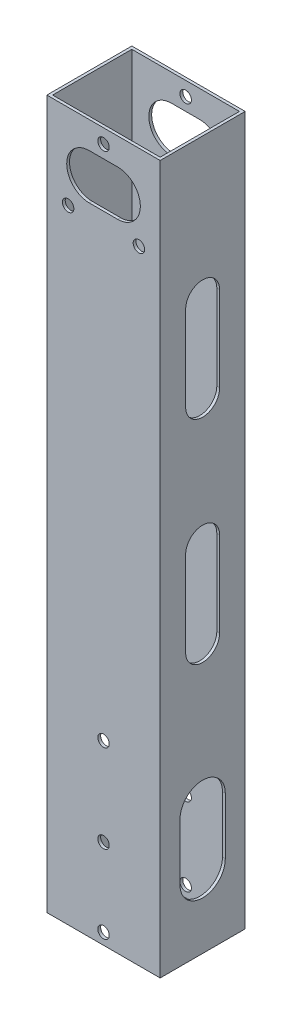
from build123d import *

# Parameters (mm, degrees)
SKETCH_1_W               = 40
SKETCH_1_H               = 30
EXTRUDE_1_DEPTH          = 125
SKETCH_2_W               = 38
SKETCH_2_H               = 28
CUT_EXTRUDE_1_DEPTH      = 126
CUT_EXTRUDE_1_DEPTH_BACK = 126
SKETCH_3_R               = 2.025
CUT_EXTRUDE_2_DEPTH      = 1
CUT_EXTRUDE_2_DEPTH_BACK = 31
SKETCH_4_R               = 2.025
CUT_EXTRUDE_3_DEPTH      = 1
CUT_EXTRUDE_3_DEPTH_BACK = 31
CUT_EXTRUDE_4_DEPTH      = 1
CUT_EXTRUDE_4_DEPTH_BACK = 41
CUT_EXTRUDE_5_DEPTH      = 1
CUT_EXTRUDE_5_DEPTH_BACK = 31
CUT_EXTRUDE_6_DEPTH      = 1
CUT_EXTRUDE_6_DEPTH_BACK = 41


with BuildPart() as part:
    # 草图1 → 凸台-拉伸1 (new body, symmetric)
    with BuildSketch(Plane(origin=(0, 0, 0), x_dir=(1, 0, 0), z_dir=(0, 1, 0))):
        Rectangle(SKETCH_1_W, SKETCH_1_H)
    extrude(amount=EXTRUDE_1_DEPTH, both=True)

    # 草图2 → 切除-拉伸1 (cut, two sides)
    with BuildSketch(Plane(origin=(0, 0, 0), x_dir=(1, 0, 0), z_dir=(0, 1, 0))) as cut_extrude_1_sk:
        Rectangle(SKETCH_2_W, SKETCH_2_H)
    extrude(amount=CUT_EXTRUDE_1_DEPTH, mode=Mode.SUBTRACT)
    extrude(cut_extrude_1_sk.sketch, amount=-CUT_EXTRUDE_1_DEPTH_BACK, mode=Mode.SUBTRACT)

    # 草图3 → 切除-拉伸2 (cut, two sides)
    with BuildSketch(Plane.XY.offset(15)) as cut_extrude_2_sk:
        with Locations((0, -62.433034374)):
            Circle(SKETCH_3_R)
        with Locations((0, -93.433034374)):
            Circle(SKETCH_3_R)
        with Locations((0, -121)):
            Circle(SKETCH_3_R)
    extrude(amount=CUT_EXTRUDE_2_DEPTH, mode=Mode.SUBTRACT)
    extrude(cut_extrude_2_sk.sketch, amount=-CUT_EXTRUDE_2_DEPTH_BACK, mode=Mode.SUBTRACT)

    # 草图4 → 切除-拉伸3 (cut, two sides)
    with BuildSketch(Plane(origin=(0, 0, -15), x_dir=(-1, 0, 0), z_dir=(0, 0, -1))) as cut_extrude_3_sk:
        with Locations((0, 120)):
            Circle(SKETCH_4_R)
        with Locations((12.5, 95)):
            Circle(SKETCH_4_R)
        with Locations((-12.5, 95)):
            Circle(SKETCH_4_R)
    extrude(amount=CUT_EXTRUDE_3_DEPTH, mode=Mode.SUBTRACT)
    extrude(cut_extrude_3_sk.sketch, amount=-CUT_EXTRUDE_3_DEPTH_BACK, mode=Mode.SUBTRACT)

    # 草图5 → 切除-拉伸4 (cut, two sides)
    with BuildSketch(Plane(origin=(20, 0, 0), x_dir=(0, 0, -1), z_dir=(1, 0, 0))) as cut_extrude_4_sk:
        with BuildLine():
            Line((-8, -100), (-8, -80))
            ThreePointArc((-8, -80), (0, -72), (8, -80))
            Line((8, -80), (8, -100))
            ThreePointArc((8, -100), (0, -108), (-8, -100))
        make_face()
    extrude(amount=CUT_EXTRUDE_4_DEPTH, mode=Mode.SUBTRACT)
    extrude(cut_extrude_4_sk.sketch, amount=-CUT_EXTRUDE_4_DEPTH_BACK, mode=Mode.SUBTRACT)

    # 草图6 → 切除-拉伸5 (cut, two sides)
    with BuildSketch(Plane(origin=(0, 0, -15), x_dir=(-1, 0, 0), z_dir=(0, 0, -1))) as cut_extrude_5_sk:
        with BuildLine():
            Line((-5, 115.5), (5, 115.5))
            ThreePointArc((5, 115.5), (13, 107.5), (5, 99.5))
            Line((5, 99.5), (-5, 99.5))
            ThreePointArc((-5, 99.5), (-13, 107.5), (-5, 115.5))
        make_face()
    extrude(amount=CUT_EXTRUDE_5_DEPTH, mode=Mode.SUBTRACT)
    extrude(cut_extrude_5_sk.sketch, amount=-CUT_EXTRUDE_5_DEPTH_BACK, mode=Mode.SUBTRACT)

    # 草图7 → 切除-拉伸6 (cut, two sides)
    with BuildSketch(Plane(origin=(20, 0, 0), x_dir=(0, 0, -1), z_dir=(1, 0, 0))) as cut_extrude_6_sk:
        with BuildLine():
            Line((-6, 45), (-6, 75))
            ThreePointArc((-6, 75), (0, 81), (6, 75))
            Line((6, 75), (6, 45))
            ThreePointArc((6, 45), (0, 39), (-6, 45))
        make_face()
        with BuildLine():
            Line((-6, -30), (-6, 0))
            ThreePointArc((-6, 0), (0, 6), (6, 0))
            Line((6, 0), (6, -30))
            ThreePointArc((6, -30), (0, -36), (-6, -30))
        make_face()
    extrude(amount=CUT_EXTRUDE_6_DEPTH, mode=Mode.SUBTRACT)
    extrude(cut_extrude_6_sk.sketch, amount=-CUT_EXTRUDE_6_DEPTH_BACK, mode=Mode.SUBTRACT)


solid = part.part
